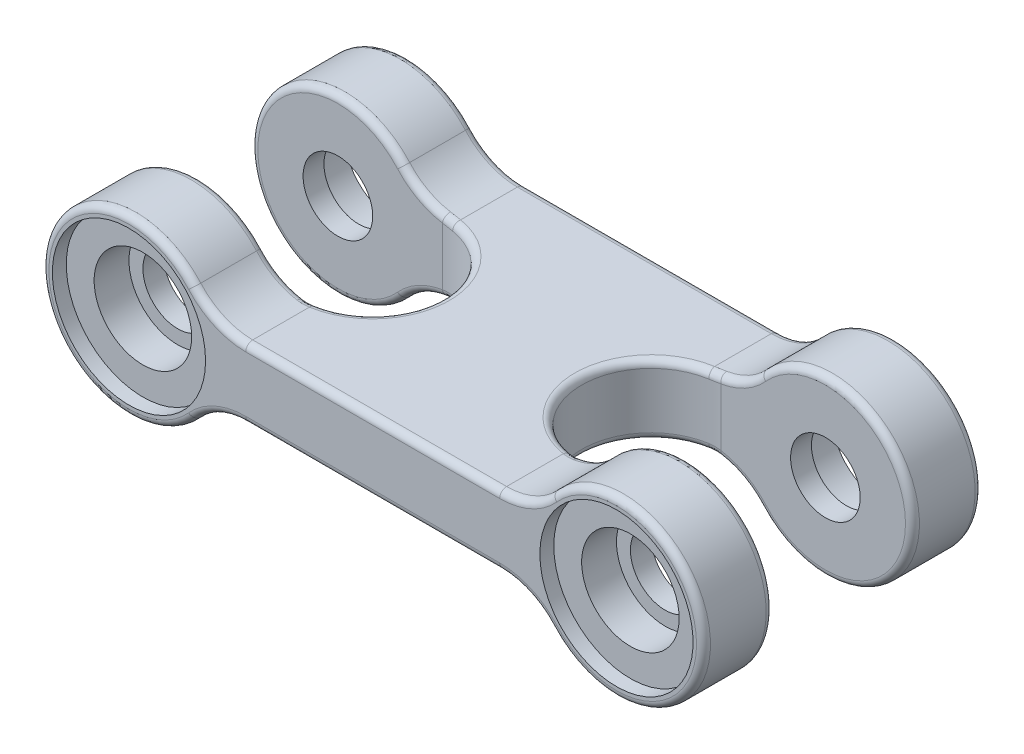
from build123d import *

# Parameters (mm, degrees)
BOSS_EXTRUDE1_DEPTH     = 20
CUT_EXTRUDE1_DEPTH      = 13.5
CUT_EXTRUDE1_DEPTH_BACK = 13.5
SKETCH3_R               = 5
CUT_EXTRUDE2_DEPTH      = 10
SKETCH4_R               = 7
CUT_EXTRUDE3_DEPTH      = 7
SKETCH5_R               = 11
CUT_EXTRUDE4_DEPTH      = 2
MIRROR2_COPY_1_SKETCH_R = 5
MIRROR2_COPY_1_DEPTH    = 10
MIRROR2_COPY_2_SKETCH_R = 7
MIRROR2_COPY_2_DEPTH    = 7
MIRROR2_COPY_3_SKETCH_R = 11
MIRROR2_COPY_3_DEPTH    = 2
FILLET1_R               = 1


with BuildPart() as part:
    # Sketch1 → Boss-Extrude1 (new body, symmetric)
    with BuildSketch(Plane.XY):
        with BuildLine():
            Line((-18.229490169, 5), (18.229490169, 5))
            ThreePointArc((18.229490169, 5), (22.311973073, 5.871290708), (25.683050094, 8.333333333))
            ThreePointArc((25.683050094, 8.333333333), (47.5, 0), (25.683050094, -8.333333333))
            ThreePointArc((25.683050094, -8.333333333), (22.311973073, -5.871290708), (18.229490169, -5))
            Line((18.229490169, -5), (-18.229490169, -5))
            ThreePointArc((-18.229490169, -5), (-22.311973073, -5.871290708), (-25.683050094, -8.333333333))
            ThreePointArc((-25.683050094, -8.333333333), (-47.5, 0), (-25.683050094, 8.333333333))
            ThreePointArc((-25.683050094, 8.333333333), (-22.311973073, 5.871290708), (-18.229490169, 5))
        make_face()
    extrude(amount=BOSS_EXTRUDE1_DEPTH, both=True)

    # Sketch2 → Cut-Extrude1 (cut, two sides)
    with BuildSketch(Plane(origin=(0, 0, 0), x_dir=(1, 0, 0), z_dir=(0, 1, 0))) as cut_extrude1_sk:
        with BuildLine():
            Line((-47.5, 10), (-20, 10))
            ThreePointArc((-20, 10), (-10, 0), (-20, -10))
            Line((-20, -10), (-47.5, -10))
            Line((-47.5, -10), (-47.5, 10))
        make_face()
        with BuildLine():
            Line((47.5, -10), (20, -10))
            ThreePointArc((20, -10), (10, 0), (20, 10))
            Line((20, 10), (47.5, 10))
            Line((47.5, 10), (47.5, -10))
        make_face()
    extrude(amount=CUT_EXTRUDE1_DEPTH, mode=Mode.SUBTRACT)
    extrude(cut_extrude1_sk.sketch, amount=-CUT_EXTRUDE1_DEPTH_BACK, mode=Mode.SUBTRACT)

    # Sketch3 → Cut-Extrude2 (cut)
    with BuildSketch(Plane.XY.offset(20)):
        with Locations((-35, 0)):
            Circle(SKETCH3_R)
    cut_extrude2 = extrude(amount=-CUT_EXTRUDE2_DEPTH, mode=Mode.SUBTRACT)

    # Sketch4 → Cut-Extrude3 (cut)
    with BuildSketch(Plane.XY.offset(20)):
        with Locations((-35, 0)):
            Circle(SKETCH4_R)
    cut_extrude3 = extrude(amount=-CUT_EXTRUDE3_DEPTH, mode=Mode.SUBTRACT)

    # Sketch5 → Cut-Extrude4 (cut)
    with BuildSketch(Plane.XY.offset(20)):
        with Locations((-35, 0)):
            Circle(SKETCH5_R)
    cut_extrude4 = extrude(amount=-CUT_EXTRUDE4_DEPTH, mode=Mode.SUBTRACT)

    # Mirror1: Cut-Extrude2, Cut-Extrude3, Cut-Extrude4 across plane
    add(cut_extrude2.mirror(Plane(origin=(0, 0, 0), x_dir=(0, 0, 1), z_dir=(1, 0, 0))), mode=Mode.SUBTRACT)
    add(cut_extrude3.mirror(Plane(origin=(0, 0, 0), x_dir=(0, 0, 1), z_dir=(1, 0, 0))), mode=Mode.SUBTRACT)
    add(cut_extrude4.mirror(Plane(origin=(0, 0, 0), x_dir=(0, 0, 1), z_dir=(1, 0, 0))), mode=Mode.SUBTRACT)

    # Mirror2: Cut-Extrude2, Cut-Extrude3, Cut-Extrude4 across plane
    add(cut_extrude2.mirror(Plane.XY), mode=Mode.SUBTRACT)
    add(cut_extrude3.mirror(Plane.XY), mode=Mode.SUBTRACT)
    add(cut_extrude4.mirror(Plane.XY), mode=Mode.SUBTRACT)

    # Mirror2 copy 1 sketch → Mirror2 copy 1 (cut)
    with BuildSketch(Plane(origin=(0, 0, -20), x_dir=(-1, 0, 0), z_dir=(0, 0, -1))):
        with Locations((-35, 0)):
            Circle(MIRROR2_COPY_1_SKETCH_R)
    extrude(amount=-MIRROR2_COPY_1_DEPTH, mode=Mode.SUBTRACT)

    # Mirror2 copy 2 sketch → Mirror2 copy 2 (cut)
    with BuildSketch(Plane(origin=(0, 0, -20), x_dir=(-1, 0, 0), z_dir=(0, 0, -1))):
        with Locations((-35, 0)):
            Circle(MIRROR2_COPY_2_SKETCH_R)
    extrude(amount=-MIRROR2_COPY_2_DEPTH, mode=Mode.SUBTRACT)

    # Mirror2 copy 3 sketch → Mirror2 copy 3 (cut)
    with BuildSketch(Plane(origin=(0, 0, -20), x_dir=(-1, 0, 0), z_dir=(0, 0, -1))):
        with Locations((-35, 0)):
            Circle(MIRROR2_COPY_3_SKETCH_R)
    extrude(amount=-MIRROR2_COPY_3_DEPTH, mode=Mode.SUBTRACT)

    # Fillet1
    fillet1_edges = [part.edges().sort_by_distance(p)[0] for p in [
        (22.311973073, -5.871290708, 20),
        (0, -5, -20),
        (-22.311973073, -5.871290708, -20),
        (47.5, 0, 20),
        (22.311973073, 5.871290708, 20),
        (0, 5, 20),
        (-22.311973073, 5.871290708, 20),
        (-47.5, 0, 20),
        (-47.5, 0, 10),
        (-47.5, 0, -10),
        (-19.114745084, 5.039260884, 9.960739116),
        (-19.114745084, 5.039260884, -9.960739116),
        (-19.114745084, -5.039260884, 9.960739116),
        (-10, -5, 0),
        (-19.114745084, -5.039260884, -9.960739116),
        (-10, 5, 0),
        (-23.107151274, 6.270256467, -10),
        (-23.107151274, -6.270256467, -10),
        (-23.107151274, -6.270256467, 10),
        (-23.107151274, 6.270256467, 10),
        (-22.311973073, -5.871290708, 20),
        (10, 5, 0),
        (23.107151274, 6.270256467, 10),
        (23.107151274, 6.270256467, -10),
        (47.5, 0, -10),
        (23.107151274, -6.270256467, -10),
        (23.107151274, -6.270256467, 10),
        (47.5, 0, 10),
        (0, -5, 20),
        (19.114745084, -5.039260884, -9.960739116),
        (10, -5, 0),
        (19.114745084, -5.039260884, 9.960739116),
        (19.114745084, 5.039260884, 9.960739116),
        (19.114745084, 5.039260884, -9.960739116),
        (-47.5, 0, -20),
        (-22.311973073, 5.871290708, -20),
        (0, 5, -20),
        (22.311973073, 5.871290708, -20),
        (47.5, 0, -20),
        (22.311973073, -5.871290708, -20),
    ]]
    fillet(fillet1_edges, radius=FILLET1_R)


solid = part.part
